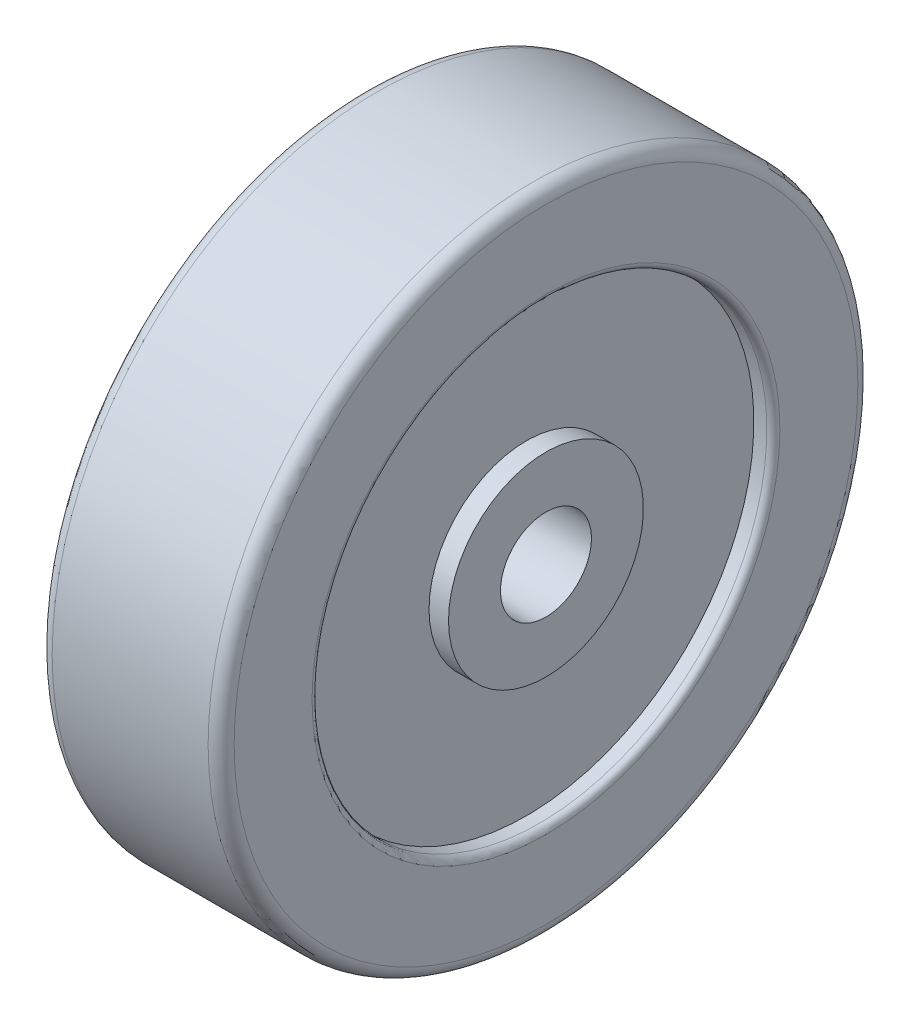
from build123d import *

# Parameters (mm, degrees)
REDONDEO1_R = 2
REDONDEO2_R = 2
REDONDEO3_R = 1
REDONDEO4_R = 1


with BuildPart() as part:
    # Croquis1 → Revolución1 (revolve)
    with BuildSketch(Plane.XY):
        Polygon((-12.649708752, 0), (15.350291248, 0), (15.350291248, 8), (12.350291248, 8), (12.350291248, 28), (15.350291248, 28), (15.350291248, 43), (-12.649708752, 43), (-12.649708752, 28), (-9.649708752, 28), (-9.649708752, 8), (-12.649708752, 8), align=None)
    revolve(axis=Axis((-30.163665743, -7, 0), (1, 0, 0)))

    # Redondeo1
    redondeo1_edges = [part.edges().sort_by_distance(p)[0] for p in [
        (15.350291248, -57, 0),
    ]]
    fillet(redondeo1_edges, radius=REDONDEO1_R)

    # Redondeo2
    redondeo2_edges = [part.edges().sort_by_distance(p)[0] for p in [
        (-12.649708752, -57, 0),
    ]]
    fillet(redondeo2_edges, radius=REDONDEO2_R)

    # Redondeo3
    redondeo3_edges = [part.edges().sort_by_distance(p)[0] for p in [
        (-12.649708752, -42, 0),
    ]]
    fillet(redondeo3_edges, radius=REDONDEO3_R)

    # Redondeo4
    redondeo4_edges = [part.edges().sort_by_distance(p)[0] for p in [
        (15.350291248, -42, 0),
    ]]
    fillet(redondeo4_edges, radius=REDONDEO4_R)


solid = part.part
